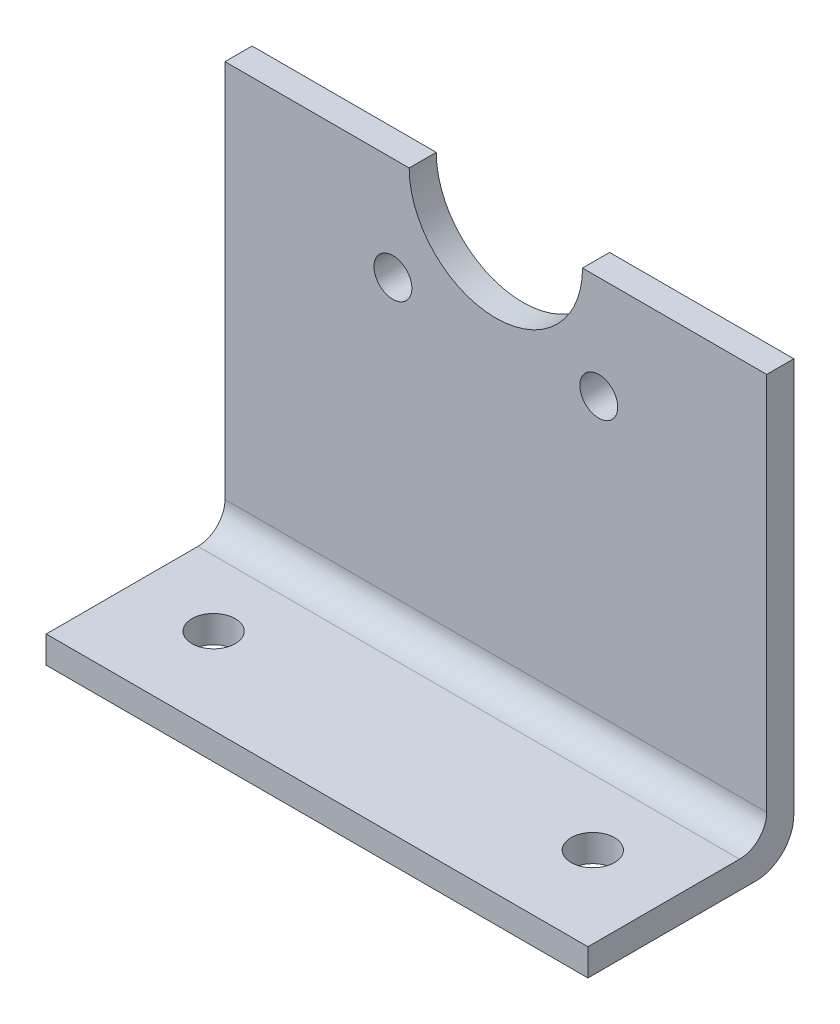
from build123d import *

# Parameters (mm, degrees)
SCHIZZO1_R                   = 3.5
ESTRUSIONE_ESTRUSIONE1_DEPTH = 5
SCHIZZO3_W                   = 100
SCHIZZO3_H                   = 38
SCHIZZO3_R                   = 4
ESTRUSIONE_ESTRUSIONE2_DEPTH = 5
RACCORDO1_R                  = 5
RACCORDO2_R                  = 7


with BuildPart() as part:
    # Schizzo1 → Estrusione-Estrusione1 (new body)
    with BuildSketch(Plane.XY):
        with BuildLine():
            Line((66, 80), (100, 80))
            Line((100, 80), (100, 0))
            Line((100, 0), (0, 0))
            Line((0, 0), (0, 80))
            Line((0, 80), (34, 80))
            ThreePointArc((34, 80), (50, 64), (66, 80))
        make_face()
        with Locations((31, 61)):
            Circle(SCHIZZO1_R, mode=Mode.SUBTRACT)
        with Locations((69, 61)):
            Circle(SCHIZZO1_R, mode=Mode.SUBTRACT)
    extrude(amount=ESTRUSIONE_ESTRUSIONE1_DEPTH)

    # Schizzo3 → Estrusione-Estrusione2 (add)
    with BuildSketch(Plane(origin=(0, 0, 0), x_dir=(1, 0, 0), z_dir=(0, 1, 0))):
        with Locations((50, -19)):
            Rectangle(SCHIZZO3_W, SCHIZZO3_H)
        with Locations((15, -22.1)):
            Circle(SCHIZZO3_R, mode=Mode.SUBTRACT)
        with Locations((85, -22.1)):
            Circle(SCHIZZO3_R, mode=Mode.SUBTRACT)
    extrude(amount=ESTRUSIONE_ESTRUSIONE2_DEPTH)

    # Raccordo1
    raccordo1_edges = [part.edges().sort_by_distance(p)[0] for p in [
        (50, 5, 5),
    ]]
    fillet(raccordo1_edges, radius=RACCORDO1_R)

    # Raccordo2
    raccordo2_edges = [part.edges().sort_by_distance(p)[0] for p in [
        (50, 0, 0),
    ]]
    fillet(raccordo2_edges, radius=RACCORDO2_R)


solid = part.part
